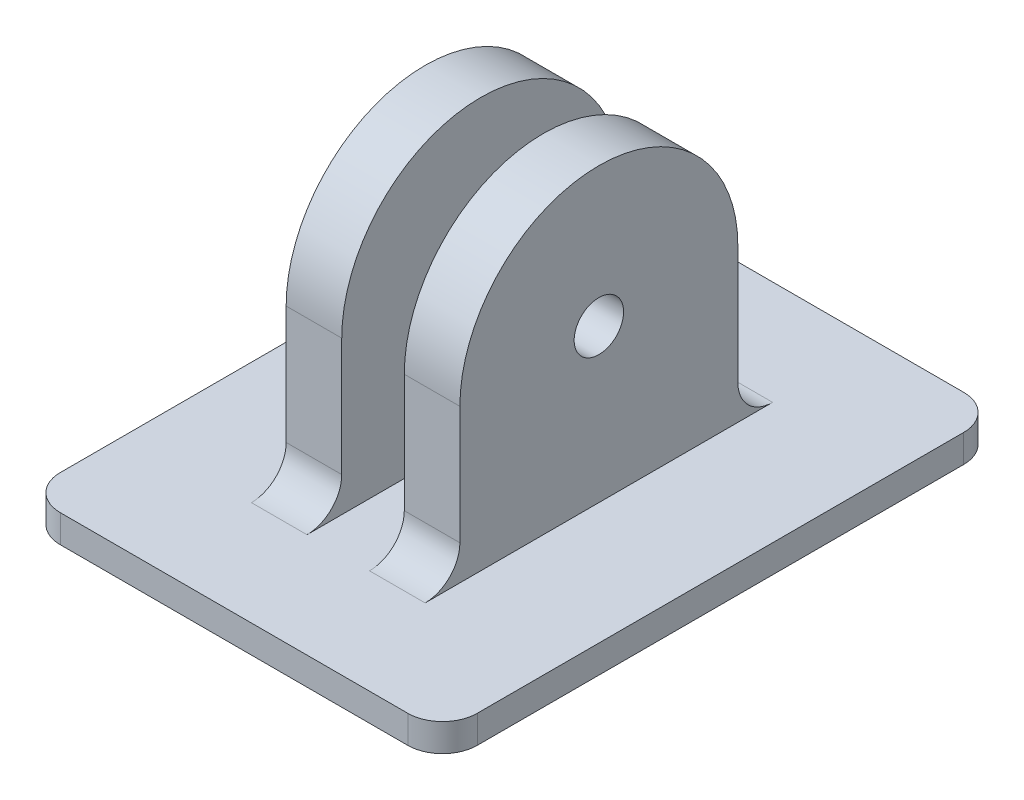
from build123d import *

# Parameters (mm, degrees)
ESQUISSE1_W             = 30
ESQUISSE1_H             = 40
BOSS_EXTRU_1_DEPTH      = 2
ESQUISSE2_W             = 4
ESQUISSE2_H             = 20
BOSS_EXTRU_2_DEPTH      = 11
BOSS_EXTRU_3_START      = -4
BOSS_EXTRU_3_DEPTH      = 4
BOSS_EXTRU_4_START      = -4
BOSS_EXTRU_4_DEPTH      = 4
ESQUISSE5_R             = 1.778
ENL_V_MAT_EXTRU_1_DEPTH = 12.5
CONG_1_R                = 2.5


with BuildPart() as part:
    # Esquisse1 → Boss.-Extru.1 (new body)
    with BuildSketch(Plane(origin=(0, 0, 0), x_dir=(1, 0, 0), z_dir=(0, 1, 0))):
        Rectangle(ESQUISSE1_W, ESQUISSE1_H)
    extrude(amount=BOSS_EXTRU_1_DEPTH)

    # Esquisse2 → Boss.-Extru.2 (add)
    with BuildSketch(Plane(origin=(0, 2, 0), x_dir=(1, 0, 0), z_dir=(0, 1, 0))):
        with Locations((4.25, 0)):
            Rectangle(ESQUISSE2_W, ESQUISSE2_H)
        with Locations((-4.25, 0)):
            Rectangle(ESQUISSE2_W, ESQUISSE2_H)
    extrude(amount=BOSS_EXTRU_2_DEPTH)

    # Esquisse3 → Boss.-Extru.3 (add)
    with BuildSketch(Plane.ZY.offset(6.25).offset(BOSS_EXTRU_3_START)):
        with BuildLine():
            Line((-10, 13), (10, 13))
            ThreePointArc((10, 13), (0, 23), (-10, 13))
        make_face()
    extrude(amount=BOSS_EXTRU_3_DEPTH)

    # Esquisse4 → Boss.-Extru.4 (add)
    with BuildSketch(Plane(origin=(6.25, 0, 0), x_dir=(0, 0, -1), z_dir=(1, 0, 0)).offset(BOSS_EXTRU_4_START)):
        with BuildLine():
            Line((10, 13), (-10, 13))
            ThreePointArc((-10, 13), (0, 23), (10, 13))
        make_face()
    extrude(amount=BOSS_EXTRU_4_DEPTH)

    # Esquisse5 → Enlèv. mat.-Extru.1 (cut)
    with BuildSketch(Plane(origin=(6.25, 0, 0), x_dir=(0, 0, -1), z_dir=(1, 0, 0))):
        with Locations((0, 13)):
            Circle(ESQUISSE5_R)
    extrude(amount=-ENL_V_MAT_EXTRU_1_DEPTH, mode=Mode.SUBTRACT)

    # Congé1
    cong_1_edges = [part.edges().sort_by_distance(p)[0] for p in [
        (4.25, 2, 10),
        (4.25, 2, -10),
        (-4.25, 2, -10),
        (-4.25, 2, 10),
        (-15, 1, -20),
        (15, 1, -20),
        (15, 1, 20),
        (-15, 1, 20),
    ]]
    fillet(cong_1_edges, radius=CONG_1_R)


solid = part.part
